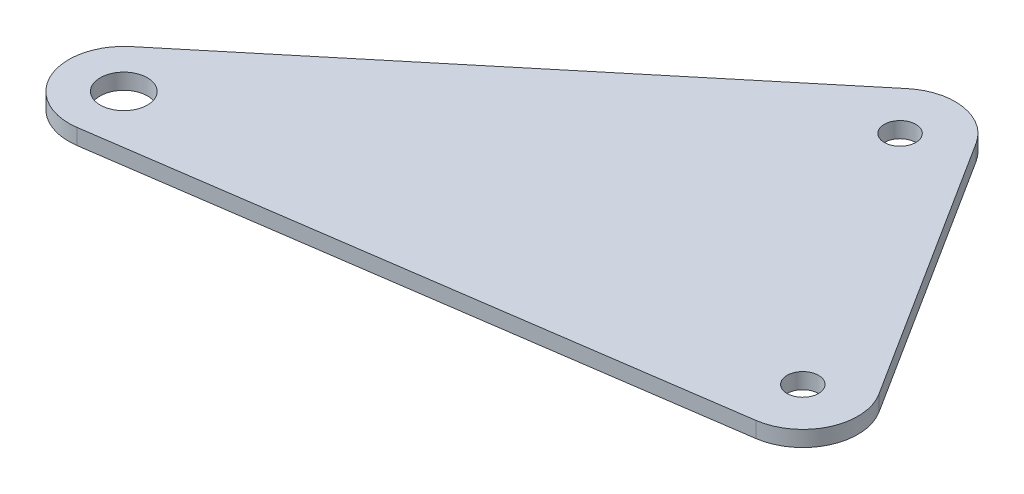
from build123d import *

# Parameters (mm, degrees)
SZKIC1_R                    = 3
SZKIC1_R_2                  = 2
DODANIE_WYCI_GNI_CIE1_DEPTH = 2


with BuildPart() as part:
    # Szkic1 → Dodanie-wyciągnięcie1 (new body)
    with BuildSketch(Plane(origin=(0, 0, 0), x_dir=(1, 0, 0), z_dir=(0, 1, 0))):
        with BuildLine():
            Line((1880.077927524, -1039.092601156), (1804.748211263, -1049.976995683))
            ThreePointArc((1804.748211263, -1049.976995683), (1797.349020556, -1045.888590036), (1799.281094114, -1037.658755553))
            Line((1799.281094114, -1037.658755553), (1853.18295757, -992.997932497))
            ThreePointArc((1853.18295757, -992.997932497), (1858.741977398, -991.473967588), (1863.559914868, -994.638244602))
            Line((1863.559914868, -994.638244602), (1884.987767673, -1028.414673131))
            ThreePointArc((1884.987767673, -1028.414673131), (1885.436779561, -1035.088900099), (1880.077927524, -1039.092601156))
        make_face()
        with Locations((1803.747176419, -1043.048941898)):
            Circle(SZKIC1_R, mode=Mode.SUBTRACT)
        with Locations((1857.649039875, -998.388118843)):
            Circle(SZKIC1_R_2, mode=Mode.SUBTRACT)
        with Locations((1879.076892681, -1032.164547372)):
            Circle(SZKIC1_R_2, mode=Mode.SUBTRACT)
    extrude(amount=DODANIE_WYCI_GNI_CIE1_DEPTH)


solid = part.part
